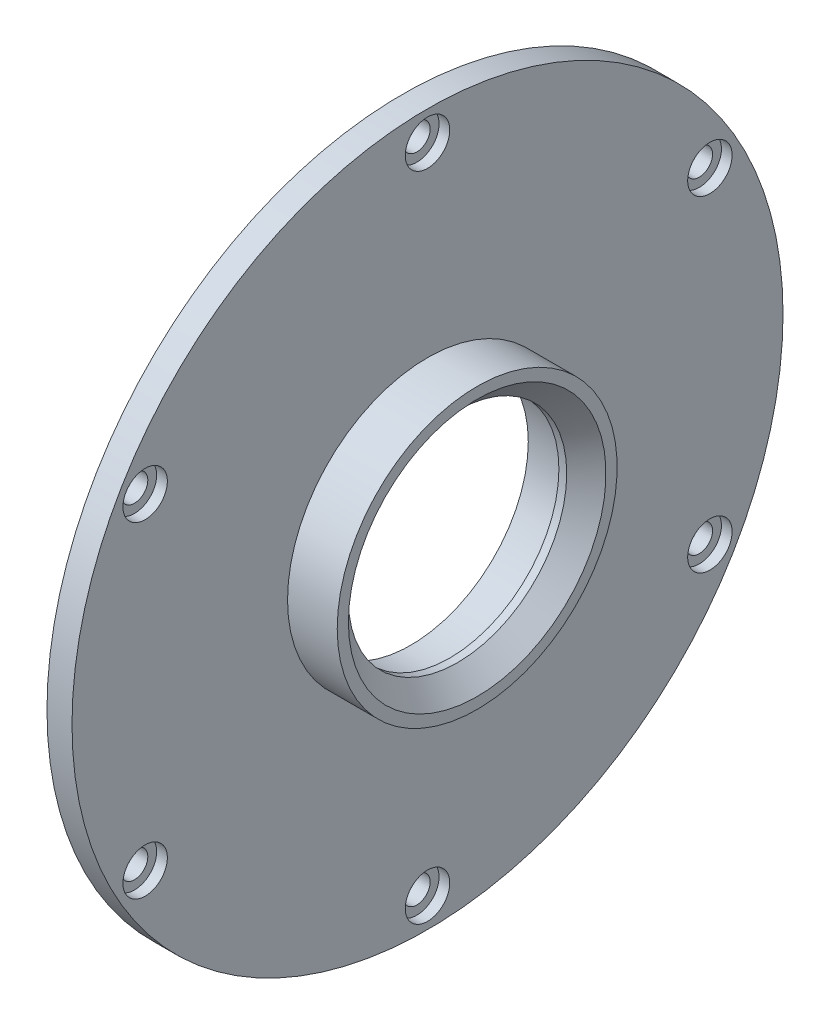
from build123d import *

# Parameters (mm, degrees)
CUT_EXTRUDE1_START = 24.0348
SKETCH7_R          = 3.96875
CUT_EXTRUDE1_DEPTH = 1.905
SKETCH8_R          = 2.38125
CUT_EXTRUDE2_DEPTH = 35.809800078


with BuildPart() as part:
    # Sketch3 → Revolve1 (revolve)
    with BuildSketch(Plane.XY):
        Polygon((34.809800078, 25.000000038), (34.809800078, 22.999999974), (31.309800093, 19.499999989), (29.909799972, 19.499999989), (29.909799972, 21.000000037), (22.939799942, 21.000000037), (22.939799942, 51.308), (21.469400038, 51.308), (21.469400038, 63.5), (25.939800038, 63.5), (25.939800038, 25.000000038), (27.839800048, 25.000000038), align=None)
    revolve(axis=Axis((0, 0, 0), (1, 0, 0)))

    # Sketch7 → Cut-Extrude1 (cut)
    with BuildSketch(Plane(origin=(0, 0, 0), x_dir=(0, 0, -1), z_dir=(1, 0, 0)).offset(CUT_EXTRUDE1_START)):
        with Locations((50.436020463, -29.119249991)):
            Circle(SKETCH7_R)
        with Locations((0, -58.238499982)):
            Circle(SKETCH7_R)
        with Locations((-50.436020463, -29.119249991)):
            Circle(SKETCH7_R)
        with Locations((-50.436020463, 29.119249991)):
            Circle(SKETCH7_R)
        with Locations((50.436020463, 29.119249991)):
            Circle(SKETCH7_R)
        with Locations((0, 58.238499982)):
            Circle(SKETCH7_R)
    extrude(amount=CUT_EXTRUDE1_DEPTH, mode=Mode.SUBTRACT)

    # Sketch8 → Cut-Extrude2 (cut, through all)
    with BuildSketch(Plane(origin=(0, 0, 0), x_dir=(0, 0, -1), z_dir=(1, 0, 0))):
        with Locations((50.436020463, 29.119249991)):
            Circle(SKETCH8_R)
        with Locations((50.436020463, -29.119249991)):
            Circle(SKETCH8_R)
        with Locations((0, -58.238499982)):
            Circle(SKETCH8_R)
        with Locations((-50.436020463, -29.119249991)):
            Circle(SKETCH8_R)
        with Locations((-50.436020463, 29.119249991)):
            Circle(SKETCH8_R)
        with Locations((0, 58.238499982)):
            Circle(SKETCH8_R)
    extrude(amount=CUT_EXTRUDE2_DEPTH, mode=Mode.SUBTRACT)


solid = part.part
